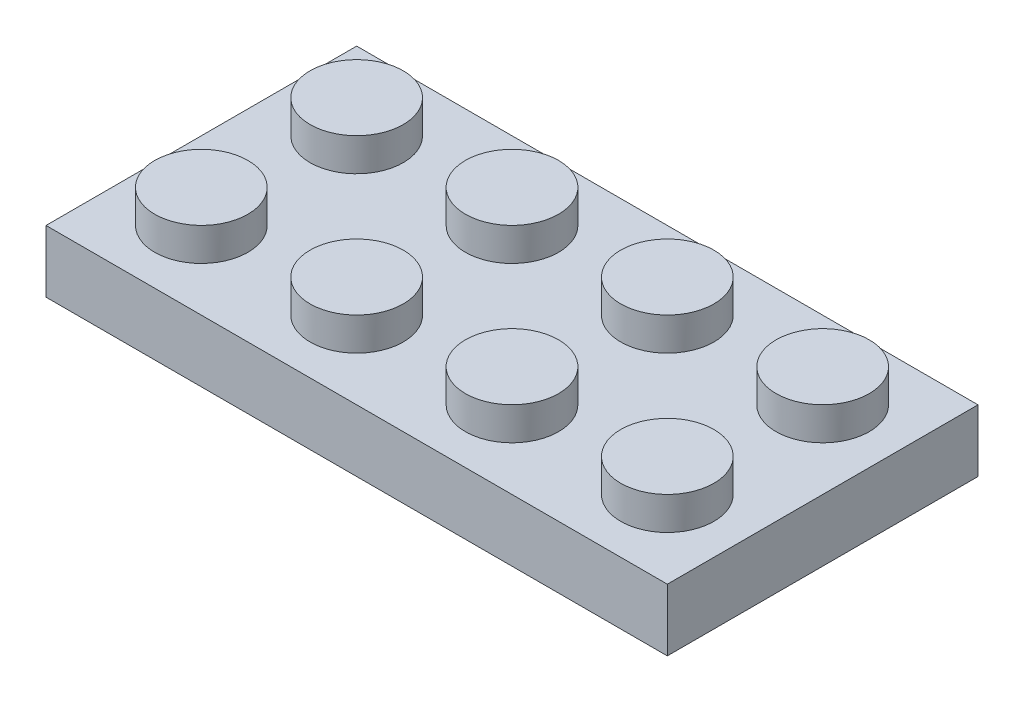
from build123d import *

# Parameters (mm, degrees)
SKETCH_1_W                       = 8
SKETCH_1_H                       = 8
HEIGHT_DEPTH                     = 3.2
SKETCH_2_R                       = 2.4
EXTRUDE_2_DEPTH                  = 1.7
PATTERN_LINEAR_1_COUNT           = 2
PATTERN_LINEAR_1_PITCH           = 8
PATTERN_LINEAR_2_COUNT           = 4
PATTERN_LINEAR_2_PITCH           = 8
PATTERN_LINEAR_2_COPY_1_SKETCH_W = 8
PATTERN_LINEAR_2_COPY_1_SKETCH_H = 8
PATTERN_LINEAR_2_COPY_1_DEPTH    = 3.2
PATTERN_LINEAR_2_COPY_2_SKETCH_W = 8
PATTERN_LINEAR_2_COPY_2_SKETCH_H = 8
PATTERN_LINEAR_2_COPY_2_DEPTH    = 3.2
PATTERN_LINEAR_2_COPY_3_SKETCH_W = 8
PATTERN_LINEAR_2_COPY_3_SKETCH_H = 8
PATTERN_LINEAR_2_COPY_3_DEPTH    = 3.2
PATTERN_LINEAR_2_COPY_4_SKETCH_R = 2.4
PATTERN_LINEAR_2_COPY_4_DEPTH    = 1.7
PATTERN_LINEAR_2_COPY_5_SKETCH_R = 2.4
PATTERN_LINEAR_2_COPY_5_DEPTH    = 1.7
PATTERN_LINEAR_2_COPY_6_SKETCH_R = 2.4
PATTERN_LINEAR_2_COPY_6_DEPTH    = 1.7
SHELL_1_T                        = -1.6
SKETCH_3_R                       = 3.255
SKETCH_3_R_2                     = 2.4
EXTRUDE_3_DEPTH                  = 1.6
PATTERN_LINEAR_3_COUNT           = 3
PATTERN_LINEAR_3_PITCH           = 8


with BuildPart() as part:
    # 草圖1 → height (new body)
    with BuildSketch(Plane(origin=(0, 0, 0), x_dir=(1, 0, 0), z_dir=(0, 1, 0))):
        Rectangle(SKETCH_1_W, SKETCH_1_H)
    height = extrude(amount=HEIGHT_DEPTH)

    # 草圖2 → 填料-伸長2 (add)
    with BuildSketch(Plane(origin=(0, 3.2, 0), x_dir=(1, 0, 0), z_dir=(0, 1, 0))):
        Circle(SKETCH_2_R)
    extrude_2 = extrude(amount=EXTRUDE_2_DEPTH)

    # 直線複製排列1: height, 填料-伸長2 ×2
    with Locations(*[(0, 0, i * PATTERN_LINEAR_1_PITCH) for i in range(1, PATTERN_LINEAR_1_COUNT)]):
        add(height)
        add(extrude_2)

    # 直線複製排列2: height, 填料-伸長2 ×4
    with Locations(*[(i * PATTERN_LINEAR_2_PITCH, 0, 0) for i in range(1, PATTERN_LINEAR_2_COUNT)]):
        add(height)
        add(extrude_2)

    # 直線複製排列2 copy 1 sketch → 直線複製排列2 copy 1 (add)
    with BuildSketch(Plane(origin=(8, 0, 8), x_dir=(1, 0, 0), z_dir=(0, 1, 0))):
        Rectangle(PATTERN_LINEAR_2_COPY_1_SKETCH_W, PATTERN_LINEAR_2_COPY_1_SKETCH_H)
    extrude(amount=PATTERN_LINEAR_2_COPY_1_DEPTH)

    # 直線複製排列2 copy 2 sketch → 直線複製排列2 copy 2 (add)
    with BuildSketch(Plane(origin=(16, 0, 8), x_dir=(1, 0, 0), z_dir=(0, 1, 0))):
        Rectangle(PATTERN_LINEAR_2_COPY_2_SKETCH_W, PATTERN_LINEAR_2_COPY_2_SKETCH_H)
    extrude(amount=PATTERN_LINEAR_2_COPY_2_DEPTH)

    # 直線複製排列2 copy 3 sketch → 直線複製排列2 copy 3 (add)
    with BuildSketch(Plane(origin=(24, 0, 8), x_dir=(1, 0, 0), z_dir=(0, 1, 0))):
        Rectangle(PATTERN_LINEAR_2_COPY_3_SKETCH_W, PATTERN_LINEAR_2_COPY_3_SKETCH_H)
    extrude(amount=PATTERN_LINEAR_2_COPY_3_DEPTH)

    # 直線複製排列2 copy 4 sketch → 直線複製排列2 copy 4 (add)
    with BuildSketch(Plane(origin=(8, 3.2, 8), x_dir=(1, 0, 0), z_dir=(0, 1, 0))):
        Circle(PATTERN_LINEAR_2_COPY_4_SKETCH_R)
    extrude(amount=PATTERN_LINEAR_2_COPY_4_DEPTH)

    # 直線複製排列2 copy 5 sketch → 直線複製排列2 copy 5 (add)
    with BuildSketch(Plane(origin=(16, 3.2, 8), x_dir=(1, 0, 0), z_dir=(0, 1, 0))):
        Circle(PATTERN_LINEAR_2_COPY_5_SKETCH_R)
    extrude(amount=PATTERN_LINEAR_2_COPY_5_DEPTH)

    # 直線複製排列2 copy 6 sketch → 直線複製排列2 copy 6 (add)
    with BuildSketch(Plane(origin=(24, 3.2, 8), x_dir=(1, 0, 0), z_dir=(0, 1, 0))):
        Circle(PATTERN_LINEAR_2_COPY_6_SKETCH_R)
    extrude(amount=PATTERN_LINEAR_2_COPY_6_DEPTH)

    # 薄殼1
    shell_1_openings = [part.faces().sort_by_distance(p)[0] for p in [
        (12, 0, 4),
    ]]
    offset(amount=SHELL_1_T, openings=shell_1_openings, kind=Kind.INTERSECTION)

    # 草圖3 → 填料-伸長3 (add)
    with BuildSketch(Plane.XZ.offset(-1.6)):
        with Locations((4, 4)):
            Circle(SKETCH_3_R)
        with Locations((4, 4)):
            Circle(SKETCH_3_R_2, mode=Mode.SUBTRACT)
    extrude_3 = extrude(amount=EXTRUDE_3_DEPTH)

    # 直線複製排列3: 填料-伸長3 ×3
    with Locations(*[(i * PATTERN_LINEAR_3_PITCH, 0, 0) for i in range(1, PATTERN_LINEAR_3_COUNT)]):
        add(extrude_3)


solid = part.part
